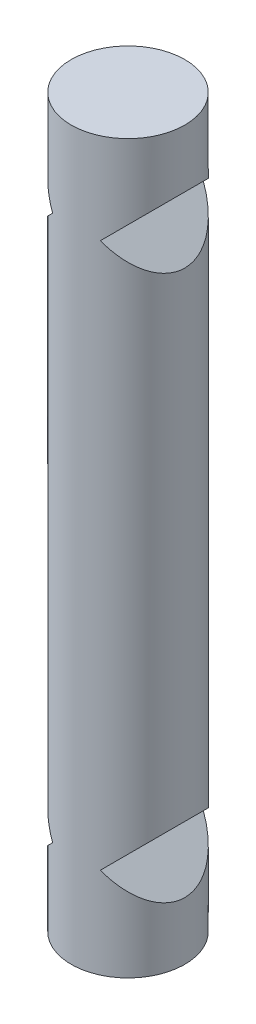
from build123d import *

# Parameters (mm, degrees)
SKETCH1_R               = 1.25
BOSS_EXTRUDE1_DEPTH     = 6
SKETCH2_R               = 1.25
BOSS_EXTRUDE2_DEPTH     = 5
SKETCH3_R               = 1.25
BOSS_EXTRUDE3_DEPTH     = 5
CUT_EXTRUDE1_DEPTH      = 2.25
CUT_EXTRUDE1_DEPTH_BACK = 2.25


with BuildPart() as part:
    # Sketch1 → Boss-Extrude1 (new body)
    with BuildSketch(Plane(origin=(0, 0, 0), x_dir=(1, 0, 0), z_dir=(0, 1, 0))):
        Circle(SKETCH1_R)
    extrude(amount=BOSS_EXTRUDE1_DEPTH)

    # Sketch2 → Boss-Extrude2 (add)
    with BuildSketch(Plane.XZ):
        Circle(SKETCH2_R)
    extrude(amount=BOSS_EXTRUDE2_DEPTH)

    # Sketch3 → Boss-Extrude3 (add)
    with BuildSketch(Plane(origin=(0, 6, 0), x_dir=(1, 0, 0), z_dir=(0, 1, 0))):
        Circle(SKETCH3_R)
    extrude(amount=BOSS_EXTRUDE3_DEPTH)

    # Sketch4 → Cut-Extrude1 (cut, two sides)
    with BuildSketch(Plane.XY) as cut_extrude1_sk:
        Polygon((0.524763121, 9), (1.25, 9.725236879), (1.25, 8.274763121), align=None)
        Polygon((-0.524763121, 9), (-1.25, 8.274763121), (-1.25, 9.725236879), align=None)
        Polygon((-0.524763121, -3), (-1.25, -3.725236879), (-1.25, -2.274763121), align=None)
        Polygon((0.524763121, -3), (1.25, -2.274763121), (1.25, -3.725236879), align=None)
    extrude(amount=CUT_EXTRUDE1_DEPTH, mode=Mode.SUBTRACT)
    extrude(cut_extrude1_sk.sketch, amount=-CUT_EXTRUDE1_DEPTH_BACK, mode=Mode.SUBTRACT)


solid = part.part
